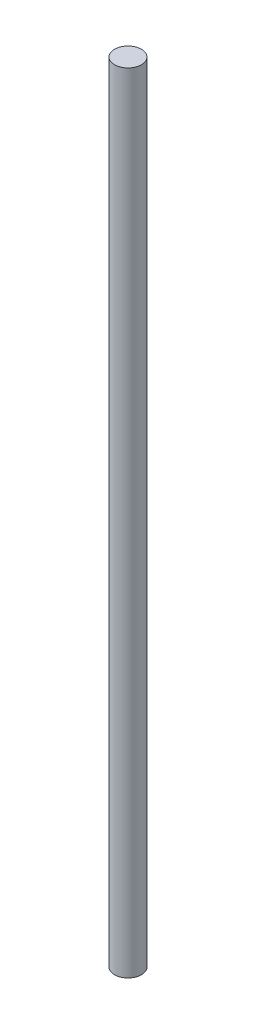
from build123d import *

# Parameters (mm, degrees)
SKETCH1_R           = 12.5
BOSS_EXTRUDE1_DEPTH = 732.5


with BuildPart() as part:
    # Sketch1 → Boss-Extrude1 (new body)
    with BuildSketch(Plane(origin=(0, 0, 0), x_dir=(1, 0, 0), z_dir=(0, 1, 0))):
        Circle(SKETCH1_R)
    extrude(amount=BOSS_EXTRUDE1_DEPTH)


solid = part.part
